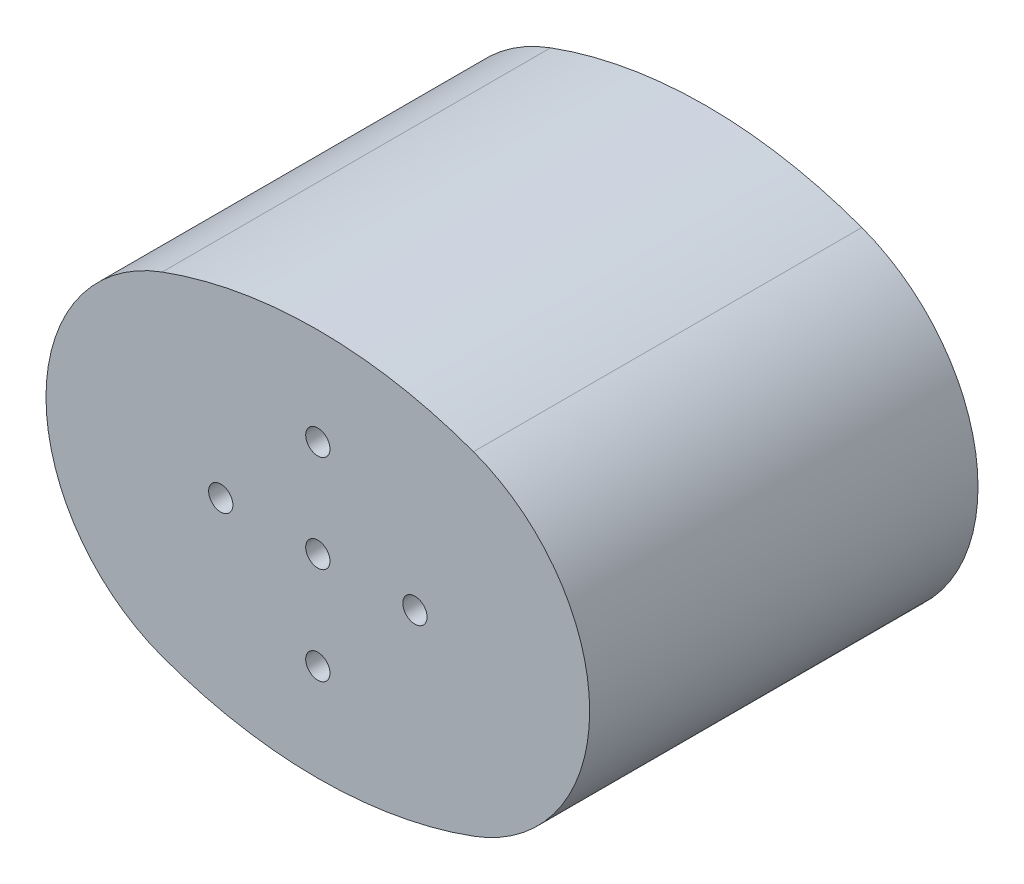
from build123d import *

# Parameters (mm, degrees)
BOSS_EXTRUDE1_DEPTH = 40
SKETCH2_R           = 1.25
CUT_EXTRUDE1_DEPTH  = 41


with BuildPart() as part:
    # Sketch1 → Boss-Extrude1 (new body)
    with BuildSketch(Plane.XY):
        with BuildLine():
            ThreePointArc((-16.03038595, 17.148754429), (-28, 0), (-16.03038595, -17.148754429))
            ThreePointArc((-16.03038595, -17.148754429), (0, -20), (16.03038595, -17.148754429))
            ThreePointArc((16.03038595, -17.148754429), (28, 0), (16.03038595, 17.148754429))
            ThreePointArc((16.03038595, 17.148754429), (0, 20), (-16.03038595, 17.148754429))
        make_face()
    extrude(amount=BOSS_EXTRUDE1_DEPTH)

    # Sketch2 → Cut-Extrude1 (cut, through all)
    with BuildSketch(Plane.XY.offset(40)):
        with Locations((0, 10)):
            Circle(SKETCH2_R)
        with Locations((10, 0)):
            Circle(SKETCH2_R)
        with Locations((0, -10)):
            Circle(SKETCH2_R)
        with Locations((-10, 0)):
            Circle(SKETCH2_R)
        Circle(SKETCH2_R)
    extrude(amount=-CUT_EXTRUDE1_DEPTH, mode=Mode.SUBTRACT)


solid = part.part
